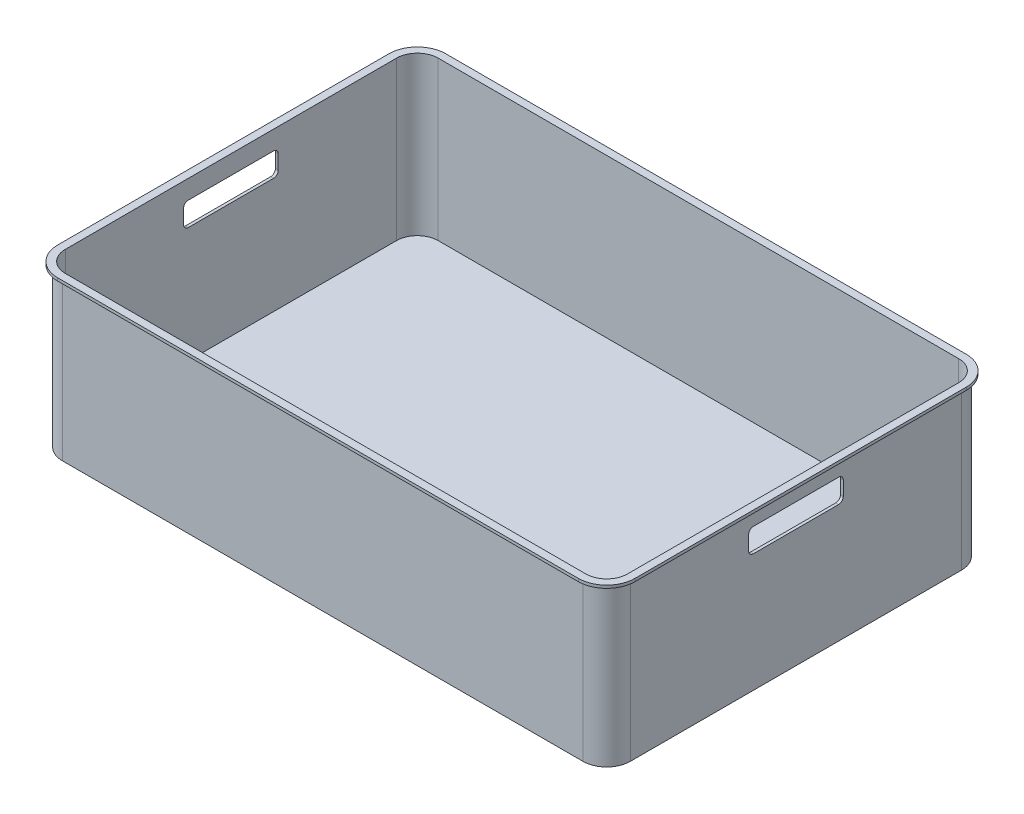
from build123d import *

# Parameters (mm, degrees)
SKETCH1_W               = 600
SKETCH1_H               = 400
BOSS_EXTRUDE1_DEPTH     = 170
FILLET1_R               = 25
SHELL1_T                = -3
EXTRUDE_THIN1_DEPTH     = 3
CUT_EXTRUDE2_DEPTH      = 1000
CUT_EXTRUDE2_DEPTH_BACK = 1000


with BuildPart() as part:
    # Sketch1 → Boss-Extrude1 (new body)
    with BuildSketch(Plane(origin=(0, 0, 0), x_dir=(1, 0, 0), z_dir=(0, 1, 0))):
        with Locations((300, 200)):
            Rectangle(SKETCH1_W, SKETCH1_H)
    extrude(amount=BOSS_EXTRUDE1_DEPTH)

    # Fillet1
    fillet1_edges = [part.edges().sort_by_distance(p)[0] for p in [
        (0, 85, -400),
        (600, 85, -400),
        (600, 85, 0),
        (0, 85, 0),
    ]]
    fillet(fillet1_edges, radius=FILLET1_R)

    # Shell1
    shell1_openings = [part.faces().sort_by_distance(p)[0] for p in [
        (300, 170, -200),
    ]]
    offset(amount=SHELL1_T, openings=shell1_openings, kind=Kind.INTERSECTION)

    # Sketch2 → Extrude-Thin1 (add)
    with BuildSketch(Plane(origin=(0, 170, 0), x_dir=(1, 0, 0), z_dir=(0, 1, 0))):
        with BuildLine():
            Line((-5, 25), (-5, 375))
            ThreePointArc((-5, 375), (3.786796564, 396.213203436), (25, 405))
            Line((25, 405), (575, 405))
            ThreePointArc((575, 405), (596.213203436, 396.213203436), (605, 375))
            Line((605, 375), (605, 25))
            ThreePointArc((605, 25), (596.213203436, 3.786796564), (575, -5))
            Line((575, -5), (25, -5))
            ThreePointArc((25, -5), (3.786796564, 3.786796564), (-5, 25))
        make_face()
        with BuildLine():
            Line((0, 25), (0, 375))
            ThreePointArc((0, 375), (7.32233047, 392.67766953), (25, 400))
            Line((25, 400), (575, 400))
            ThreePointArc((575, 400), (592.67766953, 392.67766953), (600, 375))
            Line((600, 375), (600, 25))
            ThreePointArc((600, 25), (592.67766953, 7.32233047), (575, 0))
            Line((575, 0), (25, 0))
            ThreePointArc((25, 0), (7.32233047, 7.32233047), (0, 25))
        make_face(mode=Mode.SUBTRACT)
    extrude(amount=-EXTRUDE_THIN1_DEPTH)

    # Sketch4 → Cut-Extrude2 (cut, two sides)
    with BuildSketch(Plane.ZY) as cut_extrude2_sk:
        with BuildLine():
            Line((-200, 150), (-155, 150))
            ThreePointArc((-155, 150), (-151.464466094, 148.535533906), (-150, 145))
            Line((-150, 145), (-150, 130))
            ThreePointArc((-150, 130), (-151.464466094, 126.464466094), (-155, 125))
            Line((-155, 125), (-245, 125))
            ThreePointArc((-245, 125), (-248.535533906, 126.464466094), (-250, 130))
            Line((-250, 130), (-250, 145))
            ThreePointArc((-250, 145), (-248.535533906, 148.535533906), (-245, 150))
            Line((-245, 150), (-200, 150))
        make_face()
    extrude(amount=CUT_EXTRUDE2_DEPTH, mode=Mode.SUBTRACT)
    extrude(cut_extrude2_sk.sketch, amount=-CUT_EXTRUDE2_DEPTH_BACK, mode=Mode.SUBTRACT)


solid = part.part
